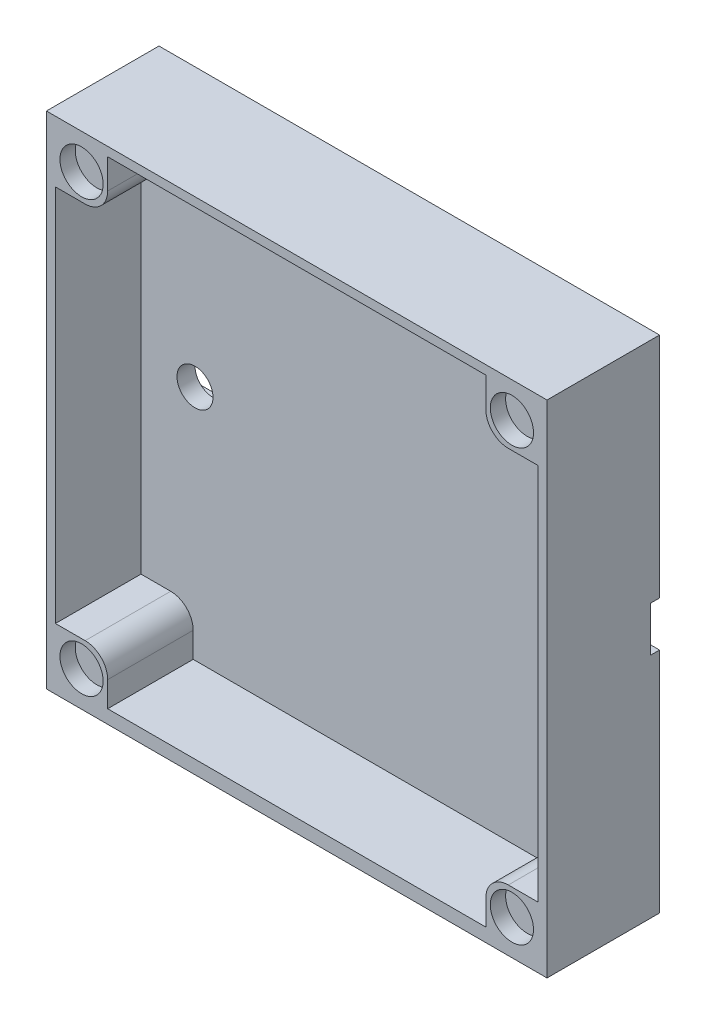
from build123d import *

# Parameters (mm, degrees)
SKICA1_W                 = 55.6
SKICA1_H                 = 55.6
P_IDAT_VYSUNUT_M2_DEPTH  = 3
SKICA5_W                 = 55.6
SKICA5_H                 = 5
ODEBRAT_VYSUNUT_M3_DEPTH = 1
SKICA14_W                = 53.6
SKICA14_H                = 1.5
P_IDAT_VYSUNUT_M9_DEPTH  = 9.5
SKICA17_R                = 2
ODEBRAT_VYSUNUT_M8_DEPTH = 4
SKICA19_W                = 6.8
SKICA19_H                = 6.8
P_IDAT_VYSUNUT_M10_DEPTH = 12.5
SKICA20_R                = 2.4
ODEBRAT_VYSUNUT_M9_DEPTH = 1.7
ZAOBLIT1_R               = 2.5


with BuildPart() as part:
    # Skica1 → Přidat vysunutím2 (new body)
    with BuildSketch(Plane.XY):
        Rectangle(SKICA1_W, SKICA1_H)
    extrude(amount=P_IDAT_VYSUNUT_M2_DEPTH)

    # Skica5 → Odebrat vysunutím3 (cut)
    with BuildSketch(Plane(origin=(0, 0, 0), x_dir=(-1, 0, 0), z_dir=(0, 0, -1))):
        Rectangle(SKICA5_W, SKICA5_H)
    extrude(amount=-ODEBRAT_VYSUNUT_M3_DEPTH, mode=Mode.SUBTRACT)

    # Skica14 → Přidat vysunutím9 (add)
    with BuildSketch(Plane.XY.offset(3)):
        Polygon((27.8, 27.8), (-27.8, 27.8), (-27.8, -27.8), (-26.8, -27.8), (-26.8, -26.8), (-26.8, -26.3), (-26.8, 26.8), (26.8, 26.8), (26.8, -26.3), (26.8, -27.8), (27.8, -27.8), align=None)
        with Locations((0, -27.05)):
            Rectangle(SKICA14_W, SKICA14_H)
    extrude(amount=P_IDAT_VYSUNUT_M9_DEPTH)

    # Skica17 → Odebrat vysunutím8 (cut)
    with BuildSketch(Plane(origin=(0, 0, 1), x_dir=(-1, 0, 0), z_dir=(0, 0, -1))):
        with Locations((-20.8, 0)):
            Circle(SKICA17_R)
        with Locations((20.8, 0)):
            Circle(SKICA17_R)
    extrude(amount=-ODEBRAT_VYSUNUT_M8_DEPTH, mode=Mode.SUBTRACT)

    # Skica19 → Přidat vysunutím10 (add)
    with BuildSketch(Plane(origin=(0, 0, 0), x_dir=(-1, 0, 0), z_dir=(0, 0, -1))):
        with Locations((-24.4, 24.4)):
            Rectangle(SKICA19_W, SKICA19_H)
        with Locations((24.4, 24.4)):
            Rectangle(SKICA19_W, SKICA19_H)
        with Locations((-24.4, -24.4)):
            Rectangle(SKICA19_W, SKICA19_H)
        with Locations((24.4, -24.4)):
            Rectangle(SKICA19_W, SKICA19_H)
    extrude(amount=-P_IDAT_VYSUNUT_M10_DEPTH)

    # Skica20 → Odebrat vysunutím9 (cut)
    with BuildSketch(Plane.XY.offset(12.5)):
        with Locations((-23.9, -23.9)):
            Circle(SKICA20_R)
        with Locations((-23.9, 23.9)):
            Circle(SKICA20_R)
        with Locations((23.900280565, 23.9)):
            Circle(SKICA20_R)
        with Locations((23.900280565, -23.9)):
            Circle(SKICA20_R)
    extrude(amount=-ODEBRAT_VYSUNUT_M9_DEPTH, mode=Mode.SUBTRACT)

    # Zaoblit1
    zaoblit1_edges = [part.edges().sort_by_distance(p)[0] for p in [
        (21, -21, 7.75),
        (-21, -21, 7.75),
        (21, 21, 7.75),
        (-21, 21, 7.75),
    ]]
    fillet(zaoblit1_edges, radius=ZAOBLIT1_R)


solid = part.part
